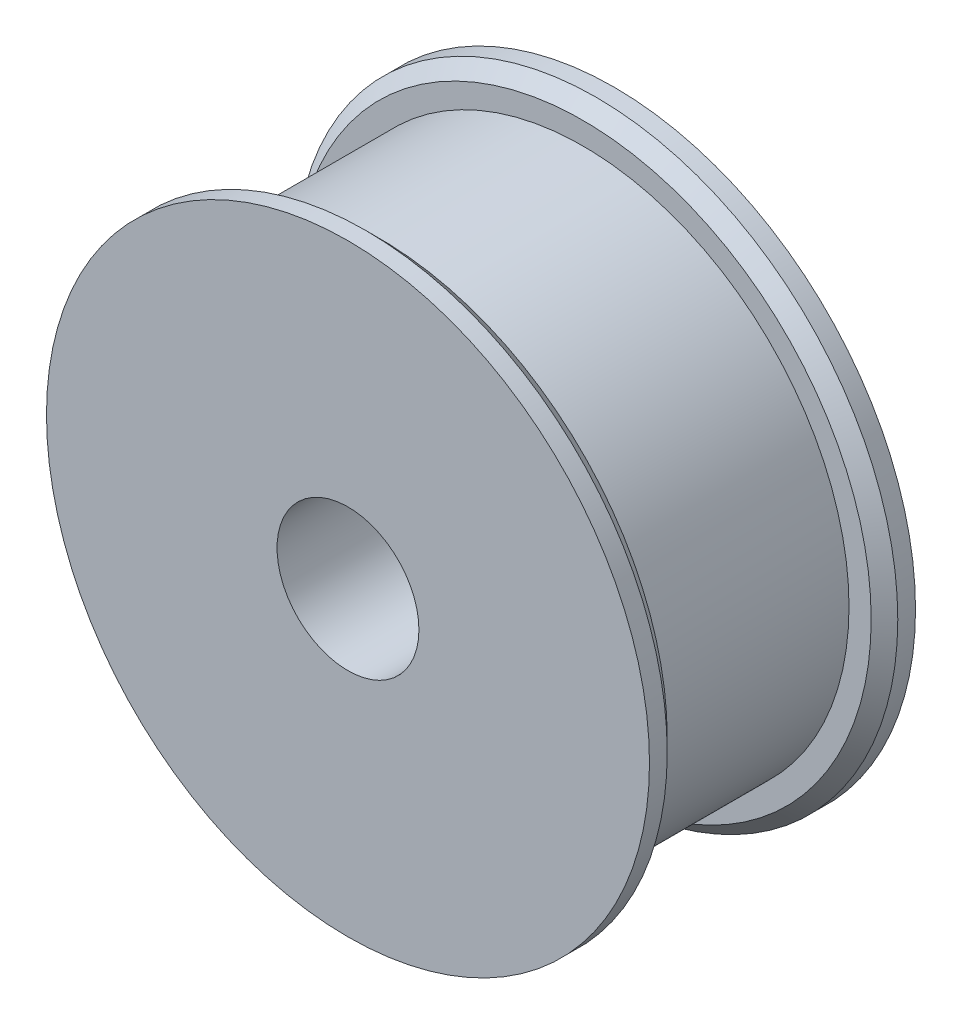
from build123d import *

# Parameters (mm, degrees)
ESQUISSE1_W     = 1.75
ESQUISSE1_H     = 2
ESQUISSE1_W_2   = 15
ESQUISSE1_H_2   = 7
CHANFREIN1_SIZE = 0.75


with BuildPart() as part:
    # Esquisse1 → Révolution1 (revolve)
    with BuildSketch(Plane(origin=(0, 0, 0), x_dir=(0, 0, -1), z_dir=(1, 0, 0))):
        Polygon((-15, 15), (-15, 11), (0, 11), (0, 15), (-1.75, 15), (-13.25, 15), align=None)
        with Locations((-14.125, 16)):
            Rectangle(ESQUISSE1_W, ESQUISSE1_H)
        with Locations((-0.875, 16)):
            Rectangle(ESQUISSE1_W, ESQUISSE1_H)
        with Locations((-7.5, 7.5)):
            Rectangle(ESQUISSE1_W_2, ESQUISSE1_H_2)
    revolve(axis=Axis((0, 0, 15), (0, 0, -1)))

    # Chanfrein1
    chanfrein1_edges = [part.edges().sort_by_distance(p)[0] for p in [
        (0, -17, 1.75),
        (0, -17, 13.25),
    ]]
    chamfer(chanfrein1_edges, length=CHANFREIN1_SIZE)


solid = part.part
